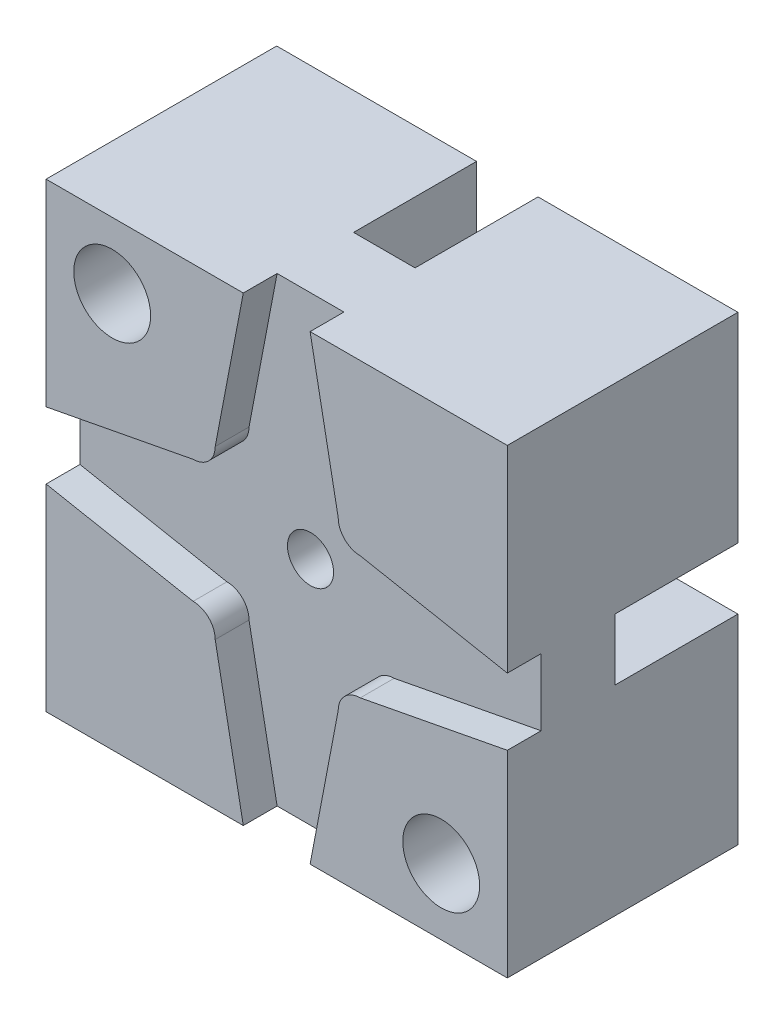
from build123d import *

# Parameters (mm, degrees)
SKETCH1_W           = 30
SKETCH1_H           = 30
BOSS_EXTRUDE1_DEPTH = 15
CUT_EXTRUDE1_DEPTH  = 15
SKETCH3_R           = 2.5
CUT_EXTRUDE2_DEPTH  = 15
SKETCH4_W           = 7
SKETCH4_H           = 4
BOSS_EXTRUDE2_DEPTH = 30
SKETCH5_W           = 4
SKETCH5_H           = 7
BOSS_EXTRUDE3_DEPTH = 30
CUT_EXTRUDE3_DEPTH  = 2.2
SKETCH7_R           = 1.5
CUT_EXTRUDE4_DEPTH  = 4.5


with BuildPart() as part:
    # Sketch1 → Boss-Extrude1 (new body)
    with BuildSketch(Plane.XY):
        Rectangle(SKETCH1_W, SKETCH1_H)
    extrude(amount=BOSS_EXTRUDE1_DEPTH)

    # Sketch2 → Cut-Extrude1 (cut)
    with BuildSketch(Plane.XY.offset(15)):
        with BuildLine():
            Line((-2, 15), (2, 15))
            Line((2, 15), (2, 10.816653826))
            ThreePointArc((2, 10.816653826), (0, 11), (-2, 10.816653826))
            Line((-2, 10.816653826), (-2, 15))
        make_face()
        with BuildLine():
            Line((15, 2), (15, -2))
            Line((15, -2), (10.816653826, -2))
            ThreePointArc((10.816653826, -2), (11, 0), (10.816653826, 2))
            Line((10.816653826, 2), (15, 2))
        make_face()
        with BuildLine():
            Line((-2, -15), (2, -15))
            Line((2, -15), (2, -10.816653826))
            ThreePointArc((2, -10.816653826), (0, -11), (-2, -10.816653826))
            Line((-2, -10.816653826), (-2, -15))
        make_face()
        with BuildLine():
            Line((-15, -2), (-15, 2))
            Line((-15, 2), (-10.816653826, 2))
            ThreePointArc((-10.816653826, 2), (-11, 0), (-10.816653826, -2))
            Line((-10.816653826, -2), (-15, -2))
        make_face()
    extrude(amount=-CUT_EXTRUDE1_DEPTH, mode=Mode.SUBTRACT)

    # Sketch3 → Cut-Extrude2 (cut)
    with BuildSketch(Plane.XY.offset(15)):
        with Locations((-10.7, 10.7)):
            Circle(SKETCH3_R)
        with Locations((10.7, -10.7)):
            Circle(SKETCH3_R)
    extrude(amount=-CUT_EXTRUDE2_DEPTH, mode=Mode.SUBTRACT)

    # Sketch4 → Boss-Extrude2 (add)
    with BuildSketch(Plane(origin=(15, 0, 0), x_dir=(0, 0, -1), z_dir=(1, 0, 0))):
        with Locations((-11.5, 0)):
            Rectangle(SKETCH4_W, SKETCH4_H)
    extrude(amount=-BOSS_EXTRUDE2_DEPTH)

    # Sketch5 → Boss-Extrude3 (add)
    with BuildSketch(Plane.XZ.offset(15)):
        with Locations((0, 11.5)):
            Rectangle(SKETCH5_W, SKETCH5_H)
    extrude(amount=-BOSS_EXTRUDE3_DEPTH)

    # Sketch6 → Cut-Extrude3 (cut)
    with BuildSketch(Plane.XY.offset(15)):
        with BuildLine():
            Line((-4, 5.437140793), (-2.172951473, 15))
            Line((-2.172951473, 15), (2.172951473, 15))
            Line((2.172951473, 15), (4, 5.437140793))
            ThreePointArc((4, 5.437140793), (4.420928793, 4.420928793), (5.437140793, 4))
            Line((5.437140793, 4), (15, 2.172951473))
            Line((15, 2.172951473), (15, -2.172951473))
            Line((15, -2.172951473), (5.437140793, -4))
            ThreePointArc((5.437140793, -4), (4.420928793, -4.420928793), (4, -5.437140793))
            Line((4, -5.437140793), (2.172951473, -15))
            Line((2.172951473, -15), (-2.172951473, -15))
            Line((-2.172951473, -15), (-4, -5.437140793))
            ThreePointArc((-4, -5.437140793), (-4.420928793, -4.420928793), (-5.437140793, -4))
            Line((-5.437140793, -4), (-15, -2.172951473))
            Line((-15, -2.172951473), (-15, 2.172951473))
            Line((-15, 2.172951473), (-5.437140793, 4))
            ThreePointArc((-5.437140793, 4), (-4.420928793, 4.420928793), (-4, 5.437140793))
        make_face()
    extrude(amount=-CUT_EXTRUDE3_DEPTH, mode=Mode.SUBTRACT)

    # Sketch7 → Cut-Extrude4 (cut)
    with BuildSketch(Plane.XY.offset(15)):
        Circle(SKETCH7_R)
    extrude(amount=-CUT_EXTRUDE4_DEPTH, mode=Mode.SUBTRACT)


solid = part.part
